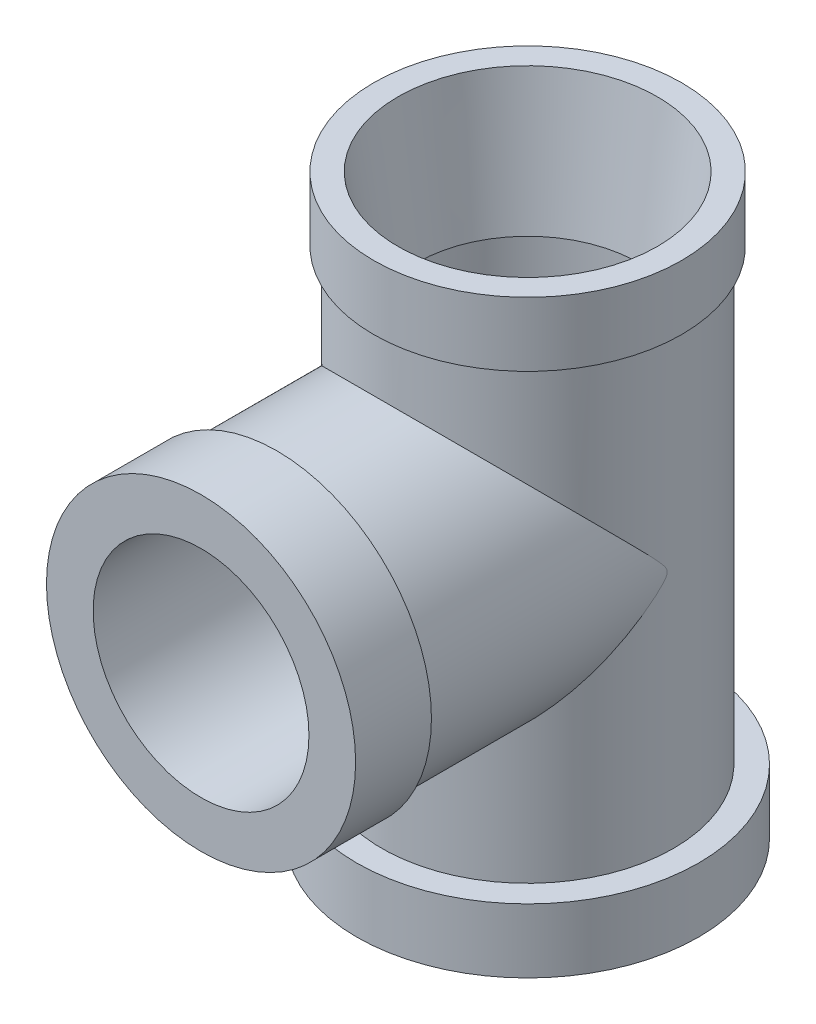
from build123d import *

# Parameters (mm, degrees)
CROQUIS2_R                 = 12.488984619
SALIENTE_EXTRUIR1_DEPTH    = 28
CROQUIS3_R                 = 9
CORTAR_EXTRUIR1_DEPTH      = 19.788850508
CORTAR_EXTRUIR1_DEPTH_BACK = 31.711149692
CROQUIS4_R                 = 13.25
SALIENTE_EXTRUIR2_DEPTH    = 6.5
CORTAR_EXTRUIR2_REACH      = 44.659
CROQUIS5_R                 = 9.25


with BuildPart() as part:
    # Croquis1 → Revolución1 (revolve)
    with BuildSketch(Plane.XY):
        Polygon((11.12, 18.788850408), (13.2, 18.788850408), (13.2, 13.288850408), (12.5, 13.288850408), (12.5, -25.211149592), (14.659269355, -25.211149592), (14.659269355, -30.711149592), (11.12, -30.711149592), (9.525, -16.252125457), (10.31589022, -16.252125457), (10.31589022, 7.254829614), (9.525, 7.254829614), align=None)
    revolve(axis=Axis((0, 29.936319964, 0), (0, -1, 0)))

    # Croquis2 → Saliente-Extruir1 (add)
    with BuildSketch(Plane.XY):
        with Locations((0, -4.438102688)):
            Circle(CROQUIS2_R)
    extrude(amount=SALIENTE_EXTRUIR1_DEPTH)

    # Croquis3 → Cortar-Extruir1 (cut, two sides)
    with BuildSketch(Plane(origin=(0, 0, 0), x_dir=(1, 0, 0), z_dir=(0, 1, 0))) as cortar_extruir1_sk:
        Circle(CROQUIS3_R)
    extrude(amount=CORTAR_EXTRUIR1_DEPTH, mode=Mode.SUBTRACT)
    extrude(cortar_extruir1_sk.sketch, amount=-CORTAR_EXTRUIR1_DEPTH_BACK, mode=Mode.SUBTRACT)

    # Croquis4 → Saliente-Extruir2 (add)
    with BuildSketch(Plane.XY.offset(28)):
        with Locations((0, -4.438102688)):
            Circle(CROQUIS4_R)
    extrude(amount=-SALIENTE_EXTRUIR2_DEPTH)

    # Croquis5 → Cortar-Extruir2 (cut, up to next)
    with BuildSketch(Plane.XY.offset(28), mode=Mode.PRIVATE) as cortar_extruir2_sk1:
        with Locations((0, -4.438102688)):
            Circle(CROQUIS5_R)
    cortar_extruir2_tool1 = extrude(cortar_extruir2_sk1.sketch, amount=-CORTAR_EXTRUIR2_REACH, mode=Mode.PRIVATE) & part.part
    add(cortar_extruir2_tool1.solids().sort_by_distance((0, -4.438103, 28))[0], mode=Mode.SUBTRACT)


solid = part.part
